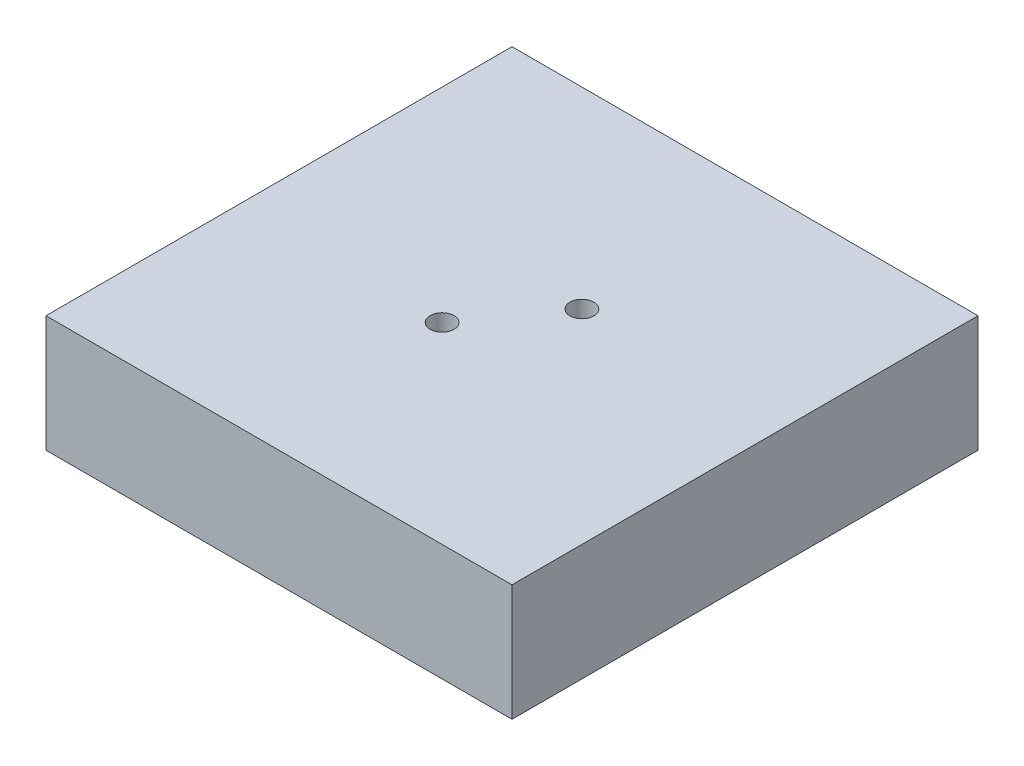
from build123d import *

# Parameters (mm, degrees)
SKETCH1_W           = 40
SKETCH1_H           = 40
BOSS_EXTRUDE1_DEPTH = 10
M2_5_TAPPED_HOLE1_D = 2.05


with BuildPart() as part:
    # Sketch1 → Boss-Extrude1 (new body)
    with BuildSketch(Plane(origin=(0, 0, 0), x_dir=(1, 0, 0), z_dir=(0, 1, 0))):
        Rectangle(SKETCH1_W, SKETCH1_H)
    extrude(amount=BOSS_EXTRUDE1_DEPTH)

    # M2.5 Tapped Hole1 (through all)
    with Locations(Plane(origin=(0, 10, 0), x_dir=(1, 0, 0), z_dir=(0, 1, 0))):
        with Locations((-2.5, -3.5), (2.5, 3.5)):
            Hole(M2_5_TAPPED_HOLE1_D / 2)


solid = part.part
